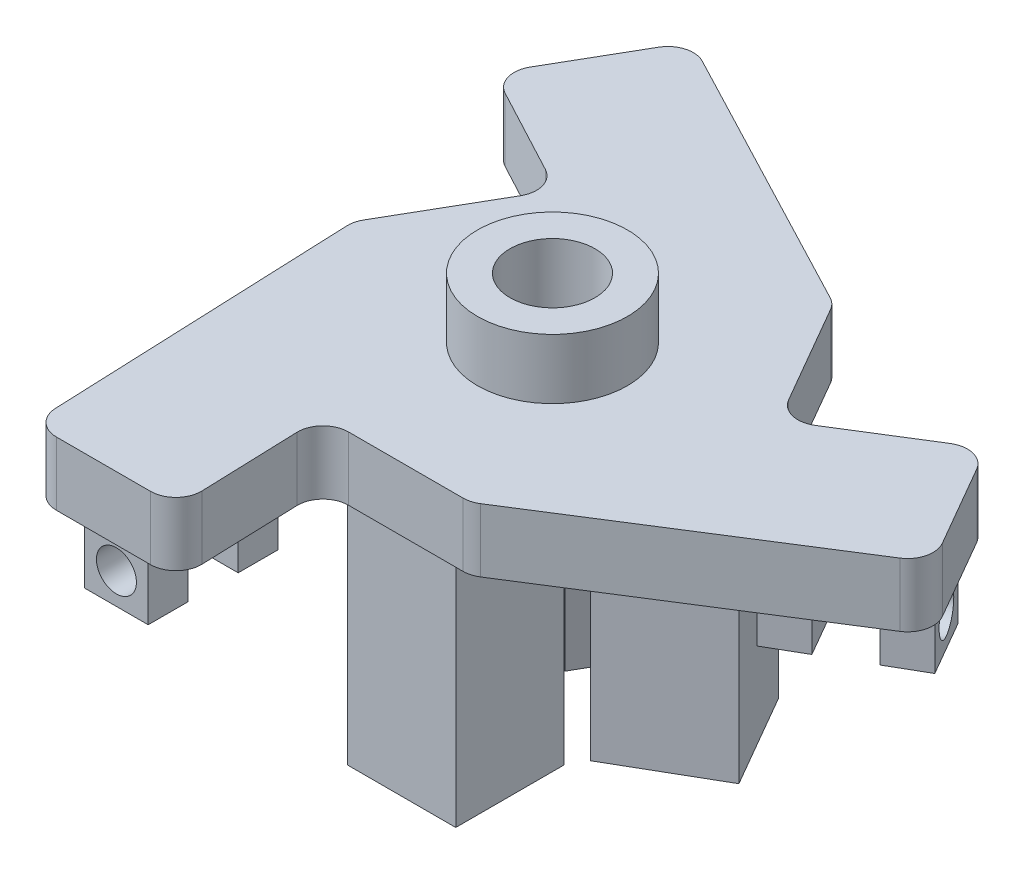
from build123d import *

# Parameters (mm, degrees)
BOSS_EXTRUDE1_DEPTH = 6.35
SKETCH6_R           = 4.250000001
CUT_EXTRUDE1_DEPTH  = 7.35
SKETCH2_W           = 6.85
SKETCH2_H           = 6.85
BOSS_EXTRUDE2_DEPTH = 25.4
SKETCH7_W           = 6.35
SKETCH7_H           = 4
BOSS_EXTRUDE3_DEPTH = 6.35
SKETCH9_R           = 2
CUT_EXTRUDE2_DEPTH  = 6.540000128
CIRPATTERN1_COUNT   = 3
SKETCH10_R          = 1.7145
CUT_EXTRUDE3_DEPTH  = 2
CIRPATTERN2_COUNT   = 3
CUT_EXTRUDE4_DEPTH  = 6.35
FILLET1_R           = 2.54
SKETCH12_R          = 7.5
SKETCH12_R_2        = 4.250000001
BOSS_EXTRUDE4_DEPTH = 6


with BuildPart() as part:
    # Sketch1 → Boss-Extrude1 (new body)
    with BuildSketch(Plane(origin=(0, 0, 0), x_dir=(1, 0, 0), z_dir=(0, 1, 0))):
        Polygon((19.05, -32.995567884), (38.1, 0), (19.05, 32.995567884), (-19.05, 32.995567884), (-38.1, 0), (-19.05, -32.995567884), align=None)
    extrude(amount=BOSS_EXTRUDE1_DEPTH)

    # Sketch6 → Cut-Extrude1 (cut, through all)
    with BuildSketch(Plane(origin=(0, 6.35, 0), x_dir=(1, 0, 0), z_dir=(0, 1, 0))):
        Circle(SKETCH6_R)
    extrude(amount=-CUT_EXTRUDE1_DEPTH, mode=Mode.SUBTRACT)

    # Sketch2 → Boss-Extrude2 (add)
    with BuildSketch(Plane.XZ):
        with BuildLine():
            Line((-5.425, 15.1), (-5.425, 4.25))
            Line((-5.425, 4.25), (-2.067021045, 4.25))
            ThreePointArc((-2.067021045, 4.25), (0, 4.726), (2.067021045, 4.25))
            Line((2.067021045, 4.25), (5.425, 4.25))
            Line((5.425, 4.25), (5.425, 15.1))
            Line((5.425, 15.1), (-5.425, 15.1))
        make_face()
        with Locations((0, 9.675)):
            Rectangle(SKETCH2_W, SKETCH2_H, mode=Mode.SUBTRACT)
        with BuildLine():
            Line((2.647097444, -3.915092735), (0.968107966, -6.823187816))
            Line((0.968107966, -6.823187816), (10.364483597, -12.248187816))
            Line((10.364483597, -12.248187816), (15.789483597, -2.851812184))
            Line((15.789483597, -2.851812184), (6.393107966, 2.573187816))
            Line((6.393107966, 2.573187816), (4.714118489, -0.334907265))
            ThreePointArc((4.714118489, -0.334907265), (4.092836058, -2.363), (2.647097444, -3.915092735))
        make_face()
        Polygon((13.05743279, -3.583862992), (7.125158774, -0.158862992), (3.700158774, -6.091137008), (9.63243279, -9.516137008), align=None, mode=Mode.SUBTRACT)
        with BuildLine():
            Line((-4.714118489, -0.334907265), (-6.393107966, 2.573187816))
            Line((-6.393107966, 2.573187816), (-15.789483597, -2.851812184))
            Line((-15.789483597, -2.851812184), (-10.364483597, -12.248187816))
            Line((-10.364483597, -12.248187816), (-0.968107966, -6.823187816))
            Line((-0.968107966, -6.823187816), (-2.647097444, -3.915092735))
            ThreePointArc((-2.647097444, -3.915092735), (-4.092836058, -2.363), (-4.714118489, -0.334907265))
        make_face()
        Polygon((-9.63243279, -9.516137008), (-3.700158774, -6.091137008), (-7.125158774, -0.158862992), (-13.05743279, -3.583862992), align=None, mode=Mode.SUBTRACT)
    extrude(amount=BOSS_EXTRUDE2_DEPTH)

    # Sketch7 → Boss-Extrude3 (add)
    with BuildSketch(Plane.XZ):
        with Locations((-11.640300372, 20.97230006)):
            Rectangle(SKETCH7_W, SKETCH7_H)
        with Locations((-11.640300372, 29.97230006)):
            Rectangle(SKETCH7_W, SKETCH7_H)
        Polygon((27.296626747, 1.354008633), (24.121626747, -4.145252681), (20.657525132, -2.145252681), (23.832525132, 3.354008633), align=None)
        Polygon((31.626753766, -1.145991367), (35.090855381, -3.145991367), (31.915855381, -8.645252681), (28.451753766, -6.645252681), align=None)
        Polygon((-12.481326375, -24.306844341), (-15.656326375, -18.807583027), (-12.19222476, -16.807583027), (-9.01722476, -22.306844341), align=None)
        Polygon((-16.811453394, -26.806844341), (-20.275555009, -28.806844341), (-23.450555009, -23.307583027), (-19.986453394, -21.307583027), align=None)
    extrude(amount=BOSS_EXTRUDE3_DEPTH)

    # Sketch9 → Cut-Extrude2 (cut)
    with BuildSketch(Plane.XY.offset(31.97230006)):
        with Locations((-11.640300372, -3.262620176)):
            Circle(SKETCH9_R)
    cut_extrude2 = extrude(amount=-CUT_EXTRUDE2_DEPTH, mode=Mode.SUBTRACT)

    # CirPattern1: Cut-Extrude2 ×3 about axis
    cirpattern1_axis = Axis((0, 0, 0), (0, 1, 0))
    for i in range(1, CIRPATTERN1_COUNT):
        add(cut_extrude2.rotate(cirpattern1_axis, i * 360 / CIRPATTERN1_COUNT), mode=Mode.SUBTRACT)

    # Sketch10 → Cut-Extrude3 (cut)
    with BuildSketch(Plane.XY.offset(22.97230006)):
        with Locations((-11.640300372, -3.262620176)):
            Circle(SKETCH10_R)
    cut_extrude3 = extrude(amount=-CUT_EXTRUDE3_DEPTH, mode=Mode.SUBTRACT)

    # CirPattern2: Cut-Extrude3 ×3 about axis
    cirpattern2_axis = Axis((0, 0, 0), (0, 1, 0))
    for i in range(1, CIRPATTERN2_COUNT):
        add(cut_extrude3.rotate(cirpattern2_axis, i * 360 / CIRPATTERN2_COUNT), mode=Mode.SUBTRACT)

    # Sketch11 → Cut-Extrude4 (cut)
    with BuildSketch(Plane.XZ):
        Polygon((-38.1, 0), (-19.05, 32.995567884), (-20.416871812, -0.535432071), (-12.999443709, -13.382794406), (-26.285912957, -20.462599003), align=None)
        Polygon((19.05, 32.995567884), (38.1, 0), (9.74473813, 17.94924569), (-5.090118075, 17.94924569), (-4.578174086, 32.995567884), align=None)
        Polygon((19.05, -32.995567884), (-19.05, -32.995567884), (10.672133681, -17.413813619), (18.089561784, -4.566451284), (30.864087043, -12.532968881), align=None)
    extrude(amount=-CUT_EXTRUDE4_DEPTH, mode=Mode.SUBTRACT)

    # Fillet1
    fillet1_edges = [part.edges().sort_by_distance(p)[0] for p in [
        (38.1, 3.175, 0),
        (-19.05, 3.175, 32.995567884),
        (-19.05, 3.175, -32.995567884),
        (18.089561784, 3.175, -4.566451284),
        (10.672133681, 3.175, -17.413813619),
        (30.864087043, 3.175, -12.532968881),
        (-5.090118075, 3.175, 17.94924569),
        (9.74473813, 3.175, 17.94924569),
        (-4.578174086, 3.175, 32.995567884),
        (-12.999443709, 3.175, -13.382794406),
        (-20.416871812, 3.175, -0.535432071),
        (-26.285912957, 3.175, -20.462599003),
    ]]
    fillet(fillet1_edges, radius=FILLET1_R)

    # Sketch12 → Boss-Extrude4 (add)
    with BuildSketch(Plane(origin=(0, 6.35, 0), x_dir=(1, 0, 0), z_dir=(0, 1, 0))):
        Circle(SKETCH12_R)
        Circle(SKETCH12_R_2, mode=Mode.SUBTRACT)
    extrude(amount=BOSS_EXTRUDE4_DEPTH)


solid = part.part
